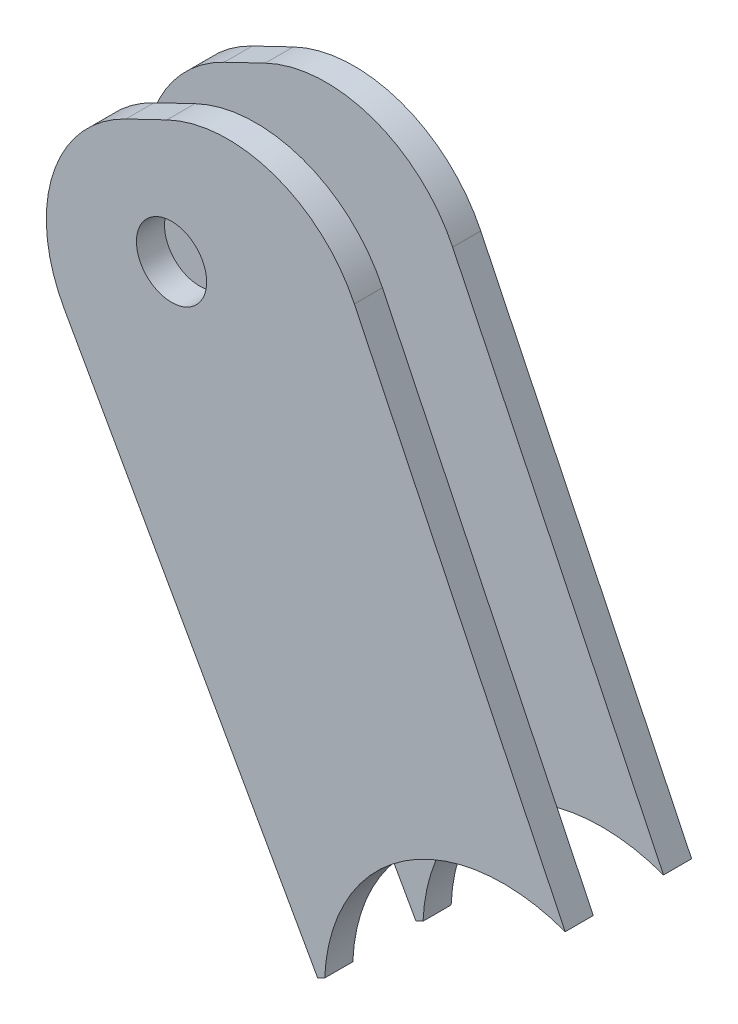
from build123d import *

# Parameters (mm, degrees)
SZKIC1_R                    = 2.5
DODANIE_WYCI_GNI_CIE1_DEPTH = 2
SZKIC2_R                    = 2.5
DODANIE_WYCI_GNI_CIE2_DEPTH = 2
SZKIC3_R                    = 12.745847425
WYTNIJ_WYCI_GNI_CIE1_DEPTH  = 12


with BuildPart() as part:
    # Szkic1 → Dodanie-wyciągnięcie1 (new body)
    with BuildSketch(Plane.XY):
        with BuildLine():
            Line((207.531644372, 219.237526191), (210.451686214, 220.642336446))
            ThreePointArc((210.451686214, 220.642336446), (218.093481617, 221.068489918), (223.798382977, 215.966260579))
            Line((223.798382977, 215.966260579), (240.051018031, 182.183495797))
            Line((240.051018031, 182.183495797), (221.183345822, 173.106400043))
            Line((221.183345822, 173.106400043), (203.140807269, 205.342048464))
            ThreePointArc((203.140807269, 205.342048464), (202.33167839, 213.239195372), (207.531644372, 219.237526191))
        make_face()
        with Locations((210.781303051, 212.057553235)):
            Circle(SZKIC1_R, mode=Mode.SUBTRACT)
    extrude(amount=DODANIE_WYCI_GNI_CIE1_DEPTH)


with BuildPart() as body_2:
    # Szkic2 → Dodanie-wyciągnięcie2 (new body)
    with BuildSketch(Plane(origin=(0, 0, -5), x_dir=(-1, 0, 0), z_dir=(0, 0, -1))):
        with BuildLine():
            Line((-240.051018031, 182.183495797), (-221.183345822, 173.106400043))
            Line((-221.183345822, 173.106400043), (-203.140807269, 205.342048464))
            ThreePointArc((-203.140807269, 205.342048464), (-202.33167839, 213.239195372), (-207.531644372, 219.237526191))
            Line((-207.531644372, 219.237526191), (-210.451686214, 220.642336446))
            ThreePointArc((-210.451686214, 220.642336446), (-218.093481617, 221.068489918), (-223.798382977, 215.966260579))
            Line((-223.798382977, 215.966260579), (-240.051018031, 182.183495797))
        make_face()
        with Locations((-210.781303051, 212.057553235)):
            Circle(SZKIC2_R, mode=Mode.SUBTRACT)
    extrude(amount=DODANIE_WYCI_GNI_CIE2_DEPTH)


with BuildPart() as wytnij_wyci_gni_cie1_tool:
    # Szkic3 → Wytnij-wyciągnięcie1 (new body)
    with BuildSketch(Plane.XY.offset(2)):
        with Locations((234.421204702, 172.795325307)):
            Circle(SZKIC3_R)
    extrude(amount=-WYTNIJ_WYCI_GNI_CIE1_DEPTH)


with BuildPart() as part_1:
    add(part.part)

    # Wytnij-wyciągnięcie1: cut by wytnij_wyci_gni_cie1_tool
    add(wytnij_wyci_gni_cie1_tool.part, mode=Mode.SUBTRACT)


with BuildPart() as body_2_1:
    add(body_2.part)

    # Wytnij-wyciągnięcie1: cut by wytnij_wyci_gni_cie1_tool
    add(wytnij_wyci_gni_cie1_tool.part, mode=Mode.SUBTRACT)


solid = Compound([part_1.part, body_2_1.part])
